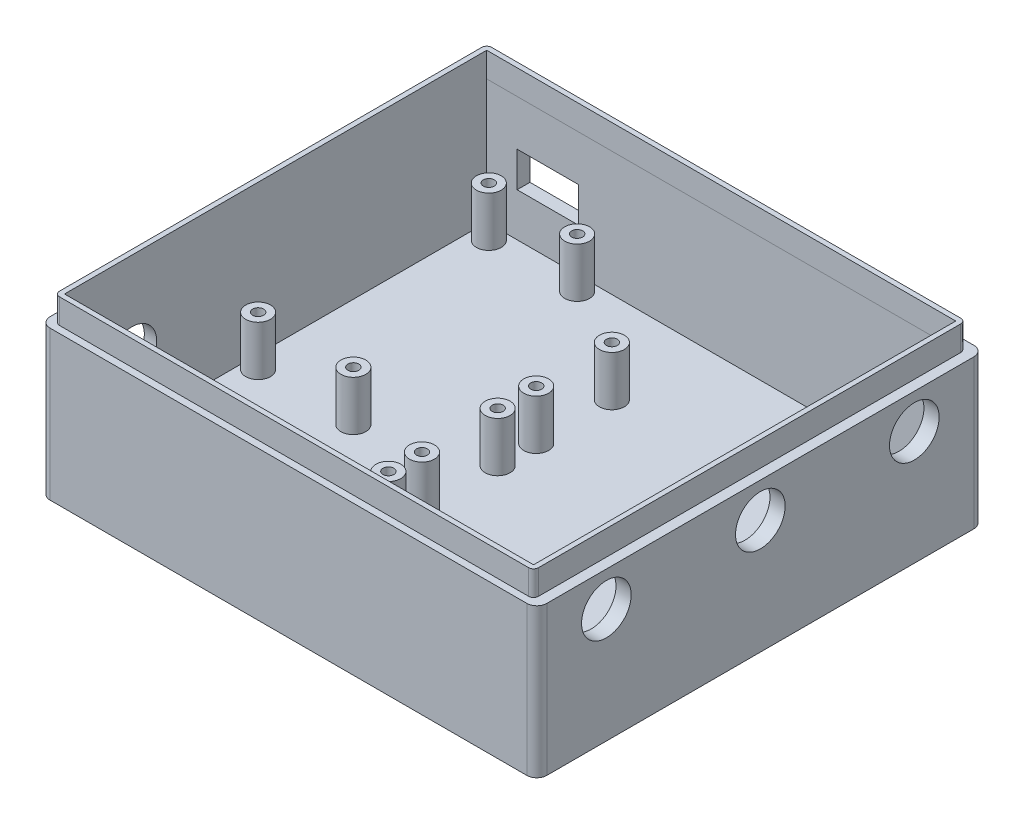
from build123d import *

# Parameters (mm, degrees)
SKETCH1_W           = 100
SKETCH1_H           = 90
BOSS_EXTRUDE1_DEPTH = 30
SKETCH3_W           = 94.435448838
SKETCH3_H           = 85
CUT_EXTRUDE1_DEPTH  = 25
FILLET2_R           = 2
SKETCH4_R           = 2.5
SKETCH4_R_2         = 2.493578604
BOSS_EXTRUDE2_DEPTH = 10
SKETCH5_R           = 1.1
CUT_EXTRUDE2_DEPTH  = 5
SKETCH7_W           = 94.435448838
SKETCH7_H           = 85
BOSS_EXTRUDE3_DEPTH = 5
SKETCH8_R           = 10
SKETCH8_R_2         = 5
CUT_EXTRUDE3_DEPTH  = 3.064551
SKETCH9_R           = 5
CUT_EXTRUDE4_DEPTH  = 2.5
SKETCH10_W          = 12.327831454
SKETCH10_H          = 7.075683127
CUT_EXTRUDE5_DEPTH  = 10


with BuildPart() as part:
    # Sketch1 → Boss-Extrude1 (new body)
    with BuildSketch(Plane(origin=(0, 0, 0), x_dir=(1, 0, 0), z_dir=(0, 1, 0))):
        with Locations((9.963784659, -32.978809591)):
            Rectangle(SKETCH1_W, SKETCH1_H)
    extrude(amount=BOSS_EXTRUDE1_DEPTH)

    # Sketch3 → Cut-Extrude1 (cut)
    with BuildSketch(Plane(origin=(0, 30, 0), x_dir=(1, 0, 0), z_dir=(0, 1, 0))):
        with Locations((9.681509078, -33.06621351)):
            Rectangle(SKETCH3_W, SKETCH3_H)
    extrude(amount=-CUT_EXTRUDE1_DEPTH, mode=Mode.SUBTRACT)

    # Fillet2
    fillet2_edges = [part.edges().sort_by_distance(p)[0] for p in [
        (-40.036215341, 15, -12.021190409),
        (59.963784659, 15, -12.021190409),
        (59.963784659, 15, 77.978809591),
        (-40.036215341, 15, 77.978809591),
    ]]
    fillet(fillet2_edges, radius=FILLET2_R)

    # Sketch4 → Boss-Extrude2 (add)
    with BuildSketch(Plane(origin=(0, 5, 0), x_dir=(1, 0, 0), z_dir=(0, 1, 0))):
        with Locations((-15.696215341, -39.257294483)):
            Circle(SKETCH4_R)
        with Locations((-16.396215341, 6.497455961)):
            Circle(SKETCH4_R)
        with Locations((-34.876215341, -39.257294483)):
            Circle(SKETCH4_R_2)
        with Locations((-34.176215341, 6.497455961)):
            Circle(SKETCH4_R)
        with Locations((6, -8.902544039)):
            Circle(SKETCH4_R)
        with Locations((6, -24.142544039)):
            Circle(SKETCH4_R)
        with Locations((6, -47.142544039)):
            Circle(SKETCH4_R)
        with Locations((6, -31.902544039)):
            Circle(SKETCH4_R)
        with Locations((6, -69.142544039)):
            Circle(SKETCH4_R)
        with Locations((6, -53.902544039)):
            Circle(SKETCH4_R)
    extrude(amount=BOSS_EXTRUDE2_DEPTH)

    # Sketch5 → Cut-Extrude2 (cut)
    with BuildSketch(Plane(origin=(0, 15, 0), x_dir=(1, 0, 0), z_dir=(0, 1, 0))):
        with Locations((-16.396215341, 6.497455961)):
            Circle(SKETCH5_R)
        with Locations((-15.696215341, -39.257294483)):
            Circle(SKETCH5_R)
        with Locations((-34.876215341, -39.257294483)):
            Circle(SKETCH5_R)
        with Locations((-34.176215341, 6.497455961)):
            Circle(SKETCH5_R)
        with Locations((6, -8.902544039)):
            Circle(SKETCH5_R)
        with Locations((6, -24.142544039)):
            Circle(SKETCH5_R)
        with Locations((6, -31.902544039)):
            Circle(SKETCH5_R)
        with Locations((6, -47.142544039)):
            Circle(SKETCH5_R)
        with Locations((6, -53.902544039)):
            Circle(SKETCH5_R)
        with Locations((6, -69.142544039)):
            Circle(SKETCH5_R)
    extrude(amount=-CUT_EXTRUDE2_DEPTH, mode=Mode.SUBTRACT)

    # Sketch7 → Boss-Extrude3 (add)
    with BuildSketch(Plane(origin=(0, 30, 0), x_dir=(1, 0, 0), z_dir=(0, 1, 0))):
        with BuildLine():
            Line((-38.536215341, 9.428748639), (-38.536215341, -75.571251361))
            ThreePointArc((-38.536215341, -75.571251361), (-38.243322123, -76.278358142), (-37.536215341, -76.571251361))
            Line((-37.536215341, -76.571251361), (56.899233497, -76.571251361))
            ThreePointArc((56.899233497, -76.571251361), (57.606340278, -76.278358142), (57.899233497, -75.571251361))
            Line((57.899233497, -75.571251361), (57.899233497, 9.428748639))
            ThreePointArc((57.899233497, 9.428748639), (57.606340278, 10.13585542), (56.899233497, 10.428748639))
            Line((56.899233497, 10.428748639), (-37.536215341, 10.428748639))
            ThreePointArc((-37.536215341, 10.428748639), (-38.243322123, 10.13585542), (-38.536215341, 9.428748639))
        make_face()
        with Locations((9.681509078, -33.071251361)):
            Rectangle(SKETCH7_W, SKETCH7_H, mode=Mode.SUBTRACT)
    extrude(amount=BOSS_EXTRUDE3_DEPTH)

    # Sketch8 → Cut-Extrude3 (cut)
    with BuildSketch(Plane(origin=(59.963784659, 0, 0), x_dir=(0, 0, -1), z_dir=(1, 0, 0))):
        with Locations((-2094.978809591, 15)):
            Circle(SKETCH8_R)
        with Locations((-1.978809591, 23)):
            Circle(SKETCH8_R_2)
        with Locations((-32.978809591, 23)):
            Circle(SKETCH8_R_2)
        with Locations((-63.978809591, 23)):
            Circle(SKETCH8_R_2)
    extrude(amount=-CUT_EXTRUDE3_DEPTH, mode=Mode.SUBTRACT)

    # Sketch9 → Cut-Extrude4 (cut)
    with BuildSketch(Plane.ZY.offset(40.036215341)):
        with Locations((62.010079566, 17.5)):
            Circle(SKETCH9_R)
    extrude(amount=-CUT_EXTRUDE4_DEPTH, mode=Mode.SUBTRACT)

    # Sketch10 → Cut-Extrude5 (cut)
    with BuildSketch(Plane(origin=(0, 0, -12.021190409), x_dir=(-1, 0, 0), z_dir=(0, 0, -1))):
        with Locations((25.252732796, 17.26805933)):
            Rectangle(SKETCH10_W, SKETCH10_H)
    extrude(amount=-CUT_EXTRUDE5_DEPTH, mode=Mode.SUBTRACT)


solid = part.part
